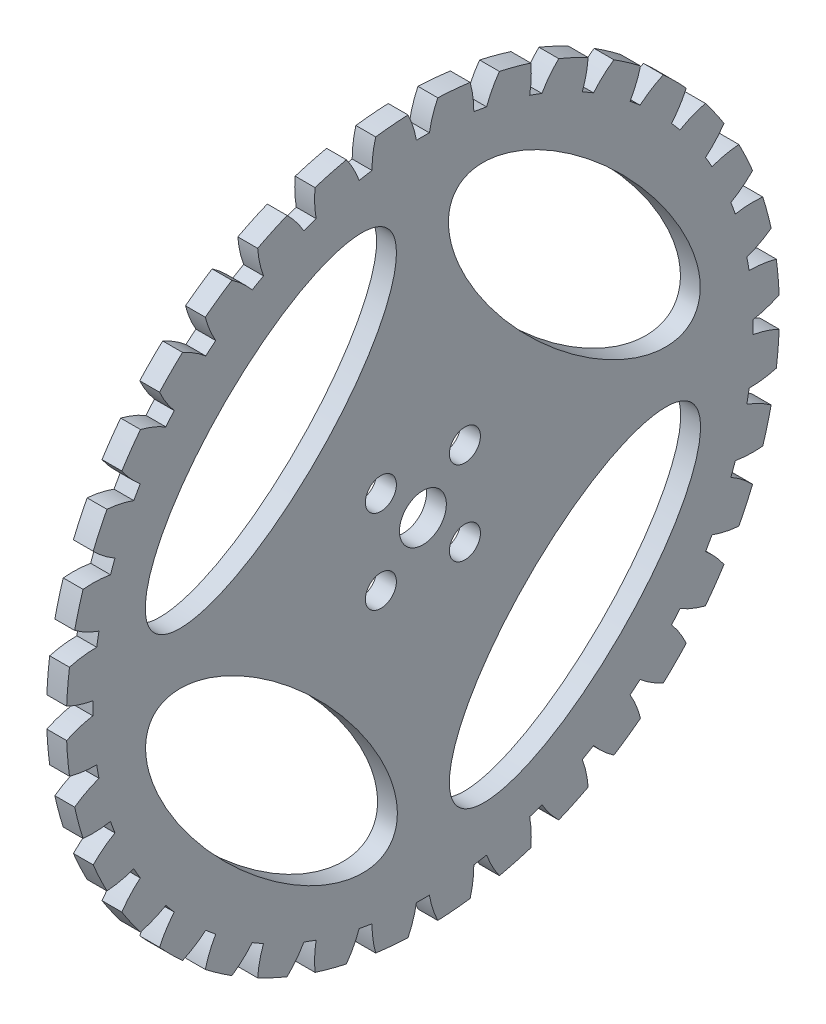
from build123d import *

# Parameters (mm, degrees)
SKIZZE1_W                        = 3
SKIZZE1_H                        = 50.45
F_4_7_4_7_DURCHMESSER_BOHRUNG1_D = 4.7
SKIZZE5_RX                       = 25
SKIZZE5_RY                       = 10
SCHNITT_LINEAR_AUSTRAGEN1_DEPTH  = 3
KREISMUSTER1_COUNT               = 4
CUT_EXTRUDE1_DEPTH               = 4
CIRPATTERN1_COUNT                = 36


with BuildPart() as part:
    # Skizze1 → Rotation1 (revolve)
    with BuildSketch(Plane.XY):
        with Locations((-39.553372853, 38.525)):
            Rectangle(SKIZZE1_W, SKIZZE1_H)
    revolve(axis=Axis((-17.6629112, 9.75, 0), (-1, 0, 0)))

    # Ø4.7 (4.7) Durchmesser Bohrung1 (through all)
    with Locations(Plane(origin=(-41.053372853, 11.968723204, 19.868936148), x_dir=(0, 0, 1), z_dir=(-1, 0, 0))):
        with Locations((-13.504975118, -8.582684234), (-26.232897179, -8.582684234), (-26.232897179, 4.145237827), (-13.504975118, 4.145237827)):
            Hole(F_4_7_4_7_DURCHMESSER_BOHRUNG1_D / 2)

    # Skizze5 → Schnitt-Linear austragen1 (cut)
    with BuildSketch(Plane(origin=(-38.053372853, 0, 0), x_dir=(0, 0, -1), z_dir=(1, 0, 0))):
        with Locations(Location((-23.027329597, 32.684515508), (0, 0, 45.090609512))):
            Ellipse(SKIZZE5_RX, SKIZZE5_RY)
    schnitt_linear_austragen1 = extrude(amount=-SCHNITT_LINEAR_AUSTRAGEN1_DEPTH, mode=Mode.SUBTRACT)

    # Kreismuster1: Schnitt-Linear austragen1 ×4 about axis
    kreismuster1_axis = Axis((0, 9.75, 0), (-1, 0, 0))
    for i in range(1, KREISMUSTER1_COUNT):
        add(schnitt_linear_austragen1.rotate(kreismuster1_axis, i * 360 / KREISMUSTER1_COUNT), mode=Mode.SUBTRACT)

    # Sketch1 → Cut-Extrude1 (cut, through all)
    with BuildSketch(Plane(origin=(-38.053372853, 0, 0), x_dir=(0, 0, -1), z_dir=(1, 0, 0))):
        with BuildLine():
            Line((-2.25, 63.703104637), (-2.25, 64.054769402))
            Line((-2.25, 64.054769402), (2.25, 64.054769402))
            Line((2.25, 64.054769402), (2.25, 63.703104637))
            ThreePointArc((2.25, 63.703104637), (1.478648887, 61.765841223), (0.983402144, 59.740328267))
            ThreePointArc((0.983402144, 59.740328267), (0, 59.75), (-0.983402144, 59.740328267))
            ThreePointArc((-0.983402144, 59.740328267), (-1.478648887, 61.765841223), (-2.25, 63.703104637))
        make_face()
    cut_extrude1 = extrude(amount=-CUT_EXTRUDE1_DEPTH, mode=Mode.SUBTRACT)

    # CirPattern1: Cut-Extrude1 ×36 about axis
    cirpattern1_axis = Axis((0, 9.75, 0), (1, 0, 0))
    for i in range(1, CIRPATTERN1_COUNT):
        add(cut_extrude1.rotate(cirpattern1_axis, i * 360 / CIRPATTERN1_COUNT), mode=Mode.SUBTRACT)


solid = part.part
